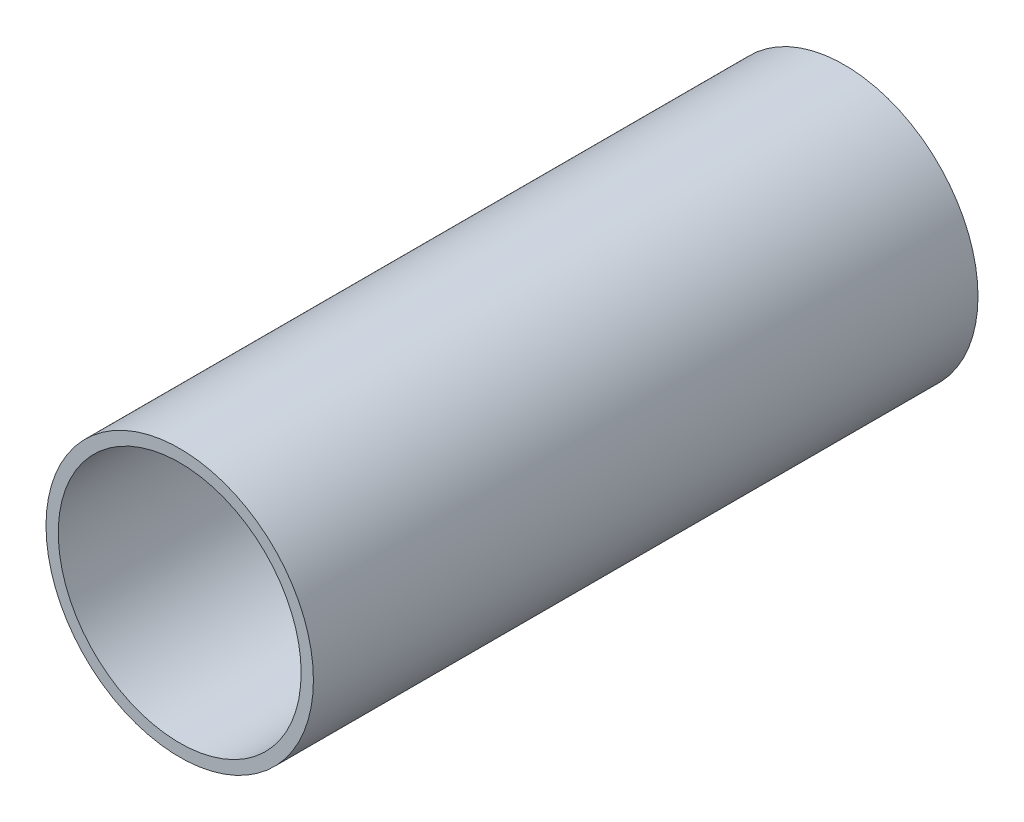
from build123d import *

# Parameters (mm, degrees)
SKETCH2_R           = 84.5
SKETCH2_R_2         = 76.75
BOSS_EXTRUDE1_DEPTH = 420


with BuildPart() as part:
    # Sketch2 → Boss-Extrude1 (new body)
    with BuildSketch(Plane.XY):
        Circle(SKETCH2_R)
        Circle(SKETCH2_R_2, mode=Mode.SUBTRACT)
    extrude(amount=BOSS_EXTRUDE1_DEPTH)


solid = part.part
